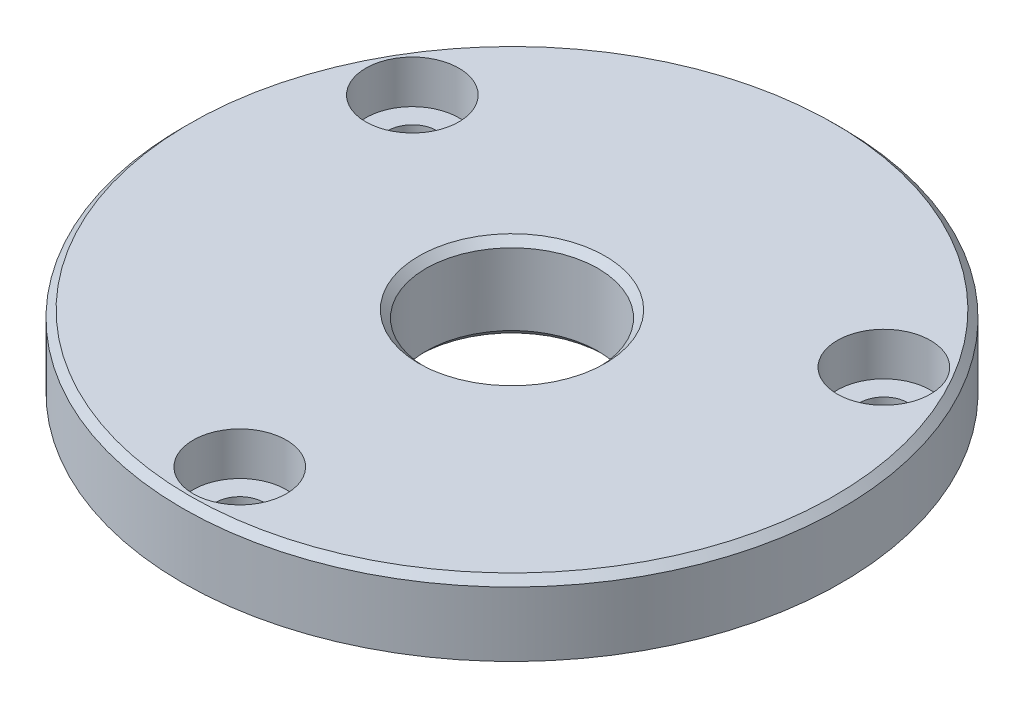
from build123d import *

# Parameters (mm, degrees)
CHANFREIN2_SIZE                                    = 0.5
CHANFREIN2_SIZE2                                   = 0.288675135
CHANFREIN3_SIZE                                    = 0.5
CHANFREIN4_SIZE                                    = 0.5
CHANFREIN5_SIZE                                    = 0.5
CHAMBRAGE_POUR_VIS_T_TE_HEXAGONALE_M31_D           = 3.4
CHAMBRAGE_POUR_VIS_T_TE_HEXAGONALE_M31_CBORE_D     = 6.5
CHAMBRAGE_POUR_VIS_T_TE_HEXAGONALE_M31_CBORE_DEPTH = 3
R_P_TITION_CIRCULAIRE1_COUNT                       = 3


with BuildPart() as part:
    # Esquisse1 → Révolution1 (revolve)
    with BuildSketch(Plane.XY, mode=Mode.PRIVATE) as r_volution1_sk:
        Polygon((11.75, 0), (15, 0), (15, 3), (23, 3), (23, 8), (6, 8), (6, 2), (11.75, 2), align=None)
    revolve(r_volution1_sk.sketch.rotate(Axis((0, 0, 0), (0, 1, 0)), 90), axis=Axis((0, 0, 0), (0, 1, 0)))  # turned: the seam where the file's is

    # Chanfrein2
    chanfrein2_edges = [part.edges().sort_by_distance(p)[0] for p in [
        (0, 0, 15),
    ]]
    chanfrein2_side = [part.faces().sort_by_distance(p)[0] for p in [
        (0, 1.5, 15),
    ]]
    chamfer(chanfrein2_edges, length=CHANFREIN2_SIZE, length2=CHANFREIN2_SIZE2, reference=chanfrein2_side[0])

    # Chanfrein3
    chanfrein3_edges = [part.edges().sort_by_distance(p)[0] for p in [
        (0, 8, 6),
    ]]
    chamfer(chanfrein3_edges, length=CHANFREIN3_SIZE)

    # Chanfrein4
    chanfrein4_edges = [part.edges().sort_by_distance(p)[0] for p in [
        (0, 2, 6),
    ]]
    chamfer(chanfrein4_edges, length=CHANFREIN4_SIZE)

    # Chanfrein5
    chanfrein5_edges = [part.edges().sort_by_distance(p)[0] for p in [
        (0, 8, 23),
    ]]
    chamfer(chanfrein5_edges, length=CHANFREIN5_SIZE)

    # Chambrage pour vis à tête hexagonale M31 (through all)
    with Locations(Plane(origin=(0, 8, 0), x_dir=(-1, 0, 0), z_dir=(0, 1, 0))):
        with Locations((0, 19)):
            chambrage_pour_vis_t_te_hexagonale_m31 = CounterBoreHole(CHAMBRAGE_POUR_VIS_T_TE_HEXAGONALE_M31_D / 2, CHAMBRAGE_POUR_VIS_T_TE_HEXAGONALE_M31_CBORE_D / 2, CHAMBRAGE_POUR_VIS_T_TE_HEXAGONALE_M31_CBORE_DEPTH)

    # Répétition circulaire1: Chambrage pour vis à tête hexagonale M31 ×3 about axis
    r_p_tition_circulaire1_axis = Axis((0, 0, 0), (0, 1, 0))
    for i in range(1, R_P_TITION_CIRCULAIRE1_COUNT):
        add(chambrage_pour_vis_t_te_hexagonale_m31.rotate(r_p_tition_circulaire1_axis, i * 360 / R_P_TITION_CIRCULAIRE1_COUNT), mode=Mode.SUBTRACT)


solid = part.part
